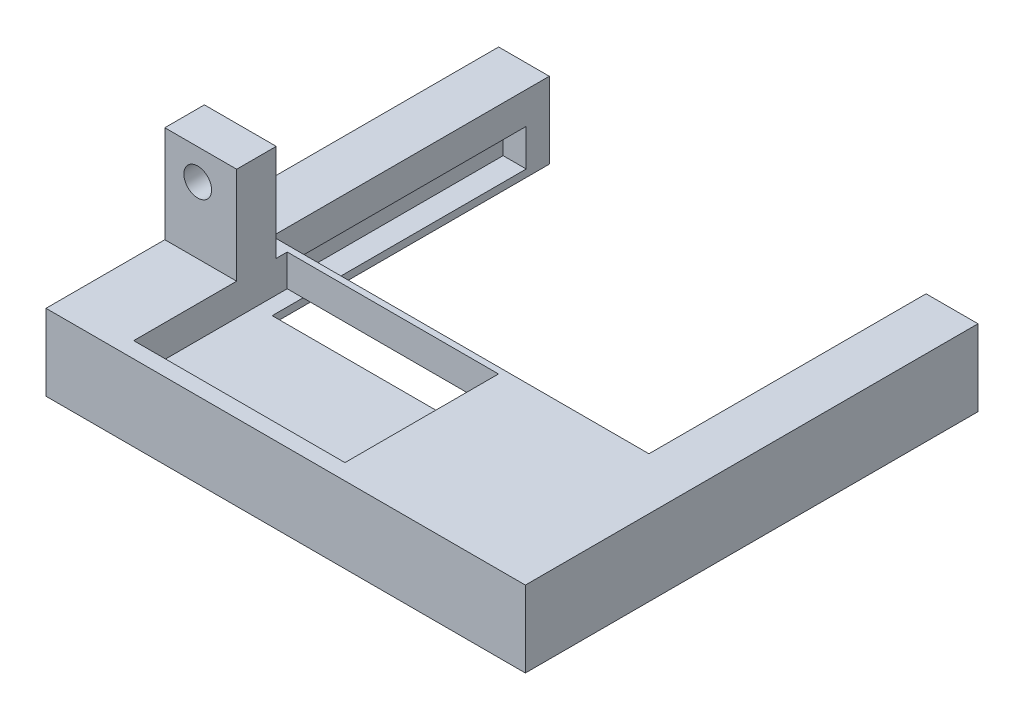
from build123d import *

# Parameters (mm, degrees)
SKETCH2_W           = 51.895920804
SKETCH2_H           = 8.246585089
BOSS_EXTRUDE1_DEPTH = 49
SKETCH3_W           = 40.788974389
SKETCH3_H           = 8.246585089
CUT_EXTRUDE1_DEPTH  = 30
SKETCH4_W           = 22.869815576
SKETCH4_H           = 16.619980412
CUT_EXTRUDE2_DEPTH  = 6
SKETCH5_W           = 27.5
SKETCH5_H           = 4
CUT_EXTRUDE3_DEPTH  = 2.5
SKETCH12_W          = 27.5
SKETCH12_H          = 4
CUT_EXTRUDE6_DEPTH  = 2.5
SKETCH15_W          = 45.788974389
SKETCH15_H          = 4
CUT_EXTRUDE7_DEPTH  = 17.5
SKETCH17_W          = 7.778908367
SKETCH17_H          = 4.284963324
BOSS_EXTRUDE2_DEPTH = 10.5
SKETCH18_R          = 1.5
CUT_EXTRUDE8_DEPTH  = 5


with BuildPart() as part:
    # Sketch2 → Boss-Extrude1 (new body)
    with BuildSketch(Plane.XY):
        with Locations((-27.854725768, 12.114483507)):
            Rectangle(SKETCH2_W, SKETCH2_H)
    extrude(amount=BOSS_EXTRUDE1_DEPTH)

    # Sketch3 → Cut-Extrude1 (cut)
    with BuildSketch(Plane(origin=(0, 0, 0), x_dir=(-1, 0, 0), z_dir=(0, 0, -1))):
        with Locations((27.921471274, 12.114483507)):
            Rectangle(SKETCH3_W, SKETCH3_H)
    extrude(amount=-CUT_EXTRUDE1_DEPTH, mode=Mode.SUBTRACT)

    # Sketch4 → Cut-Extrude2 (cut)
    with BuildSketch(Plane(origin=(0, 16.237776051, 0), x_dir=(1, 0, 0), z_dir=(0, 1, 0))):
        with Locations((-34.588870015, -38.97443395)):
            Rectangle(SKETCH4_W, SKETCH4_H)
    extrude(amount=-CUT_EXTRUDE2_DEPTH, mode=Mode.SUBTRACT)

    # Sketch5 → Cut-Extrude3 (cut)
    with BuildSketch(Plane.ZY.offset(7.52698408)):
        with Locations((16.25, 10.791190962)):
            Rectangle(SKETCH5_W, SKETCH5_H)
    extrude(amount=-CUT_EXTRUDE3_DEPTH, mode=Mode.SUBTRACT)

    # Sketch12 → Cut-Extrude6 (cut)
    with BuildSketch(Plane(origin=(-48.315958469, 0, 0), x_dir=(0, 0, -1), z_dir=(1, 0, 0))):
        with Locations((-16.25, 10.791190962)):
            Rectangle(SKETCH12_W, SKETCH12_H)
    extrude(amount=-CUT_EXTRUDE6_DEPTH, mode=Mode.SUBTRACT)

    # Sketch15 → Cut-Extrude7 (cut)
    with BuildSketch(Plane(origin=(0, 0, 30), x_dir=(-1, 0, 0), z_dir=(0, 0, -1))):
        with Locations((27.921471274, 10.791190962)):
            Rectangle(SKETCH15_W, SKETCH15_H)
    extrude(amount=-CUT_EXTRUDE7_DEPTH, mode=Mode.SUBTRACT)

    # Sketch17 → Boss-Extrude2 (add)
    with BuildSketch(Plane(origin=(0, 16.237776051, 0), x_dir=(1, 0, 0), z_dir=(0, 1, 0))):
        with Locations((-49.913231987, -33.995977251)):
            Rectangle(SKETCH17_W, SKETCH17_H)
    extrude(amount=BOSS_EXTRUDE2_DEPTH)

    # Sketch18 → Cut-Extrude8 (cut)
    with BuildSketch(Plane.XY.offset(36.138458913)):
        with Locations((-50.239621596, 23.429782287)):
            Circle(SKETCH18_R)
    extrude(amount=-CUT_EXTRUDE8_DEPTH, mode=Mode.SUBTRACT)


solid = part.part
